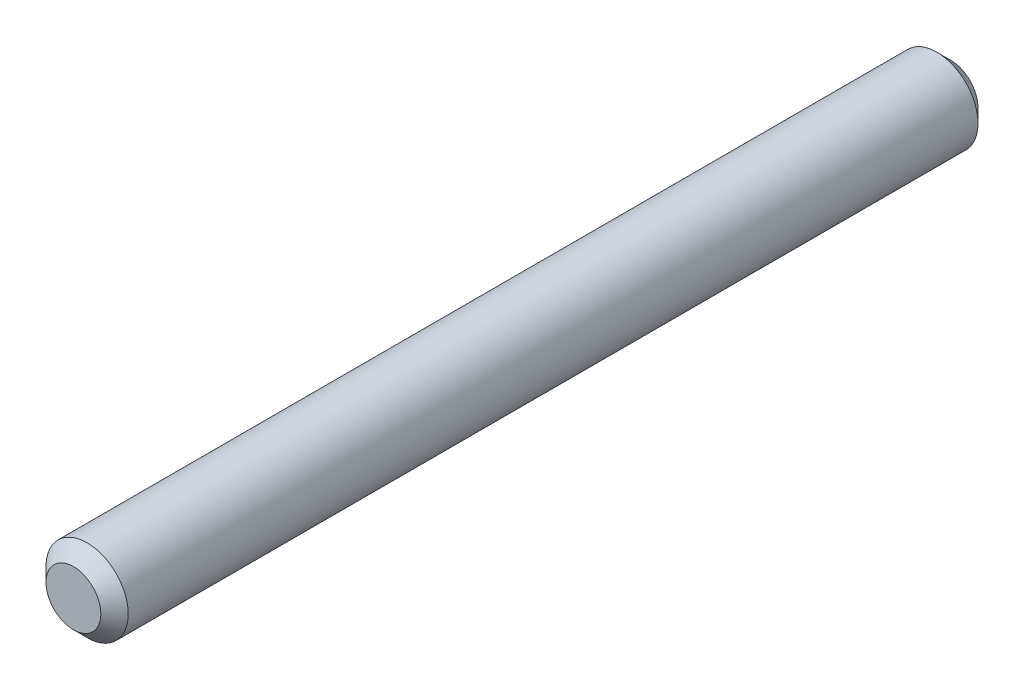
from build123d import *

# Parameters (mm, degrees)
SKETCH1_R           = 0.75
BOSS_EXTRUDE1_DEPTH = 16
CHAMFER1_SIZE       = 0.25


with BuildPart() as part:
    # Sketch1 → Boss-Extrude1 (new body)
    with BuildSketch(Plane.XY):
        Circle(SKETCH1_R)
    extrude(amount=BOSS_EXTRUDE1_DEPTH)

    # Chamfer1
    chamfer1_edges = [part.edges().sort_by_distance(p)[0] for p in [
        (-0.75, 0, 0),
        (-0.75, 0, 16),
    ]]
    chamfer(chamfer1_edges, length=CHAMFER1_SIZE)


solid = part.part
